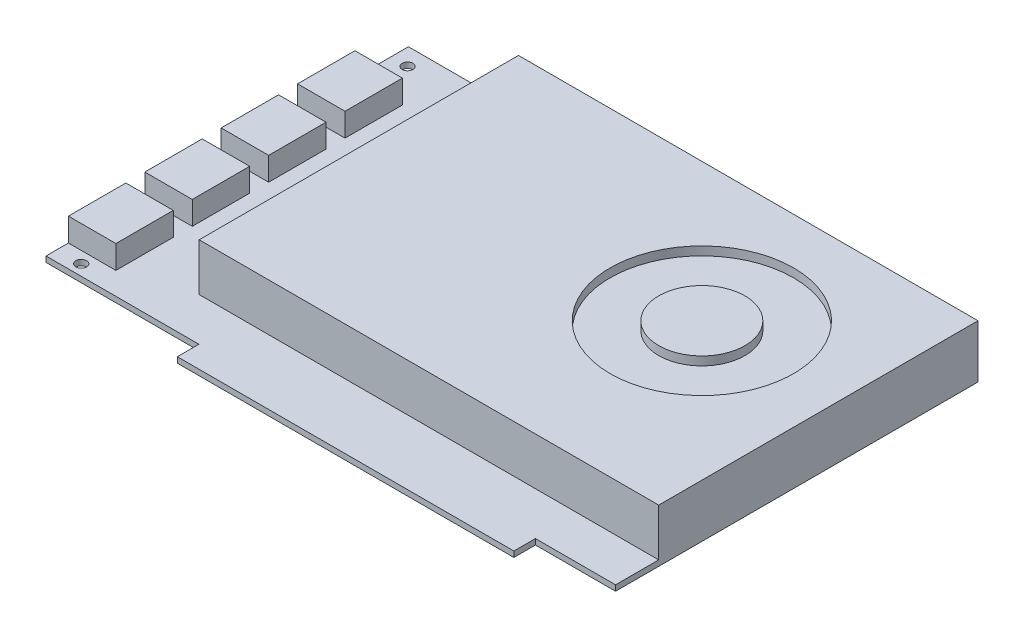
from build123d import *

# Parameters (mm, degrees)
SKETCH1_W             = 167.64
SKETCH1_H             = 106.68
SKETCH1_W_2           = 99.06
SKETCH1_H_2           = 6.35
BOSS_EXTRUDE1_DEPTH   = 1.651
SKETCH2_W             = 135.255
SKETCH2_H             = 93.98
BOSS_EXTRUDE2_DEPTH   = 13.97
F_4_CLEARANCE_HOLE1_D = 3.175
SKETCH6_W             = 13.97
SKETCH6_H             = 16.891
BOSS_EXTRUDE3_DEPTH   = 6.858
SKETCH7_W             = 2.54
SKETCH7_H             = 12.7
CUT_EXTRUDE5_DEPTH    = 2.54
LPATTERN1_COUNT       = 18
LPATTERN1_PITCH       = 5.08
SKETCH8_R             = 26.9875
SKETCH8_R_2           = 12.7
CUT_EXTRUDE6_DEPTH    = 2.54


with BuildPart() as part:
    # Sketch1 → Boss-Extrude1 (new body)
    with BuildSketch(Plane(origin=(0, 0, 0), x_dir=(1, 0, 0), z_dir=(0, 1, 0))):
        Rectangle(SKETCH1_W, SKETCH1_H)
        with Locations((10.71, -56.515)):
            Rectangle(SKETCH1_W_2, SKETCH1_H_2)
    extrude(amount=BOSS_EXTRUDE1_DEPTH)

    # Sketch2 → Boss-Extrude2 (add)
    with BuildSketch(Plane(origin=(0, 1.651, 0), x_dir=(1, 0, 0), z_dir=(0, 1, 0))):
        with Locations((16.1925, 6.35)):
            Rectangle(SKETCH2_W, SKETCH2_H)
    extrude(amount=BOSS_EXTRUDE2_DEPTH)

    # #4 Clearance Hole1 (through all)
    with Locations(Plane(origin=(-78.9305, 1.651, -48.1965), x_dir=(0, 0, 1), z_dir=(0, 1, 0))):
        with Locations((0, 0), (98.3488, 2.286)):
            Hole(F_4_CLEARANCE_HOLE1_D / 2)

    # Sketch6 → Boss-Extrude3 (add)
    with BuildSketch(Plane(origin=(0, 1.651, 0), x_dir=(1, 0, 0), z_dir=(0, 1, 0))):
        with Locations((-76.835, 29.1465)):
            Rectangle(SKETCH6_W, SKETCH6_H)
        with Locations((-76.835, 6.6675)):
            Rectangle(SKETCH6_W, SKETCH6_H)
        with Locations((-76.835, -15.8115)):
            Rectangle(SKETCH6_W, SKETCH6_H)
        with Locations((-76.835, -38.2905)):
            Rectangle(SKETCH6_W, SKETCH6_H)
    extrude(amount=BOSS_EXTRUDE3_DEPTH)

    # Sketch7 → Cut-Extrude5 (cut)
    with BuildSketch(Plane.ZY.offset(51.435)):
        with Locations((36.83, 8.636)):
            Rectangle(SKETCH7_W, SKETCH7_H)
    cut_extrude5 = extrude(amount=-CUT_EXTRUDE5_DEPTH, mode=Mode.SUBTRACT)

    # LPattern1: Cut-Extrude5 ×18
    with Locations(*[(0, 0, -i * LPATTERN1_PITCH) for i in range(1, LPATTERN1_COUNT)]):
        add(cut_extrude5, mode=Mode.SUBTRACT)

    # Sketch8 → Cut-Extrude6 (cut)
    with BuildSketch(Plane(origin=(0, 15.621, 0), x_dir=(1, 0, 0), z_dir=(0, 1, 0))):
        with Locations((43.18, 12.7)):
            Circle(SKETCH8_R)
        with Locations((43.18, 12.7)):
            Circle(SKETCH8_R_2, mode=Mode.SUBTRACT)
    extrude(amount=-CUT_EXTRUDE6_DEPTH, mode=Mode.SUBTRACT)


solid = part.part
